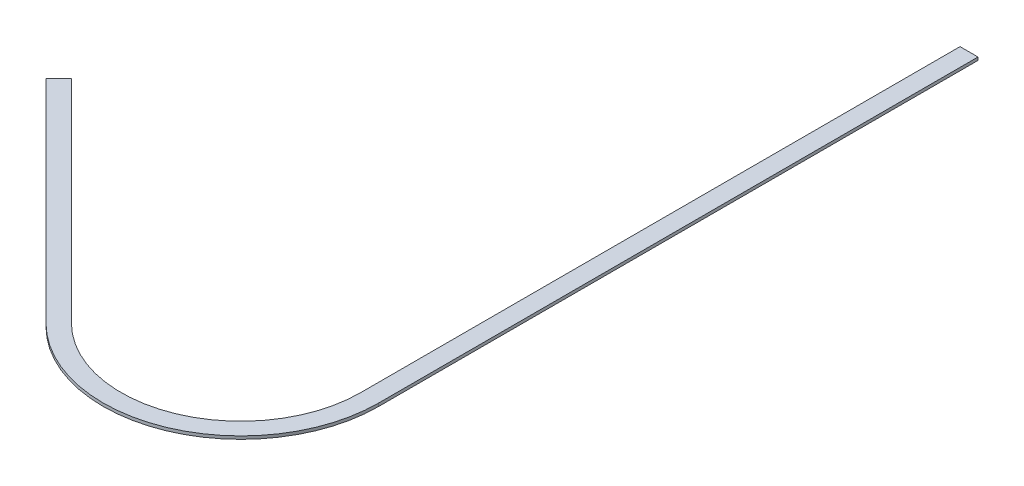
from build123d import *

# Parameters (mm, degrees)
BOSS_EXTRUDE1_DEPTH = 5


with BuildPart() as part:
    # Sketch1 → Boss-Extrude1 (new body)
    with BuildSketch(Plane(origin=(0, 0, 0), x_dir=(1, 0, 0), z_dir=(0, 1, 0))):
        with BuildLine():
            Line((0, 600), (0, -400))
            ThreePointArc((0, -400), (-123.463313527, -584.775906502), (-341.421356237, -541.421356237))
            Line((-341.421356237, -541.421356237), (-694.974746831, -187.867965644))
            Line((-694.974746831, -187.867965644), (-716.187950266, -209.08116908))
            Line((-716.187950266, -209.08116908), (-362.634559673, -562.634559673))
            ThreePointArc((-362.634559673, -562.634559673), (-111.982810556, -612.492292478), (30, -400))
            Line((30, -400), (30, 600))
            Line((30, 600), (0, 600))
        make_face()
    extrude(amount=BOSS_EXTRUDE1_DEPTH)


solid = part.part
